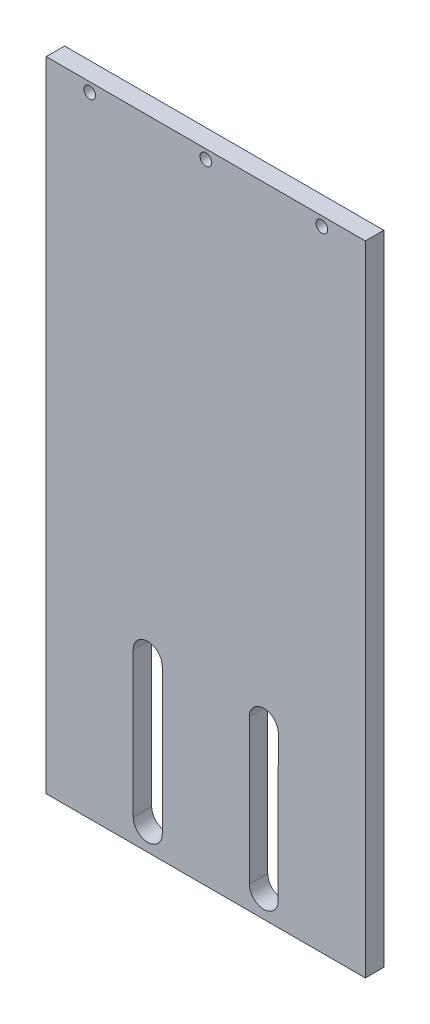
from build123d import *

# Parameters (mm, degrees)
CROQUIS1_W              = 110
CROQUIS1_H              = 220
SALIENTE_EXTRUIR1_DEPTH = 6.35
CROQUIS2_R              = 2
CORTAR_EXTRUIR2_DEPTH   = 7.35


with BuildPart() as part:
    # Croquis1 → Saliente-Extruir1 (new body)
    with BuildSketch(Plane.XY):
        Rectangle(CROQUIS1_W, CROQUIS1_H)
    extrude(amount=SALIENTE_EXTRUIR1_DEPTH)

    # Croquis2 → Cortar-Extruir2 (cut, through all)
    with BuildSketch(Plane.XY):
        with Locations((40, 106.825)):
            Circle(CROQUIS2_R)
        with Locations((-40, 106.825)):
            Circle(CROQUIS2_R)
        with Locations((0, 106.825)):
            Circle(CROQUIS2_R)
        with BuildLine():
            Line((15, -52), (15, -102))
            ThreePointArc((15, -102), (19.408343114, -106.964870807), (24.859976852, -103.175))
            Line((24.859976852, -103.175), (25, -52))
            ThreePointArc((25, -52), (20, -47), (15, -52))
        make_face()
        with BuildLine():
            Line((-25, -52), (-25, -102))
            ThreePointArc((-25, -102), (-20, -107), (-15, -102))
            Line((-15, -102), (-15, -52))
            ThreePointArc((-15, -52), (-20, -47), (-25, -52))
        make_face()
    extrude(amount=CORTAR_EXTRUIR2_DEPTH, mode=Mode.SUBTRACT)


solid = part.part
